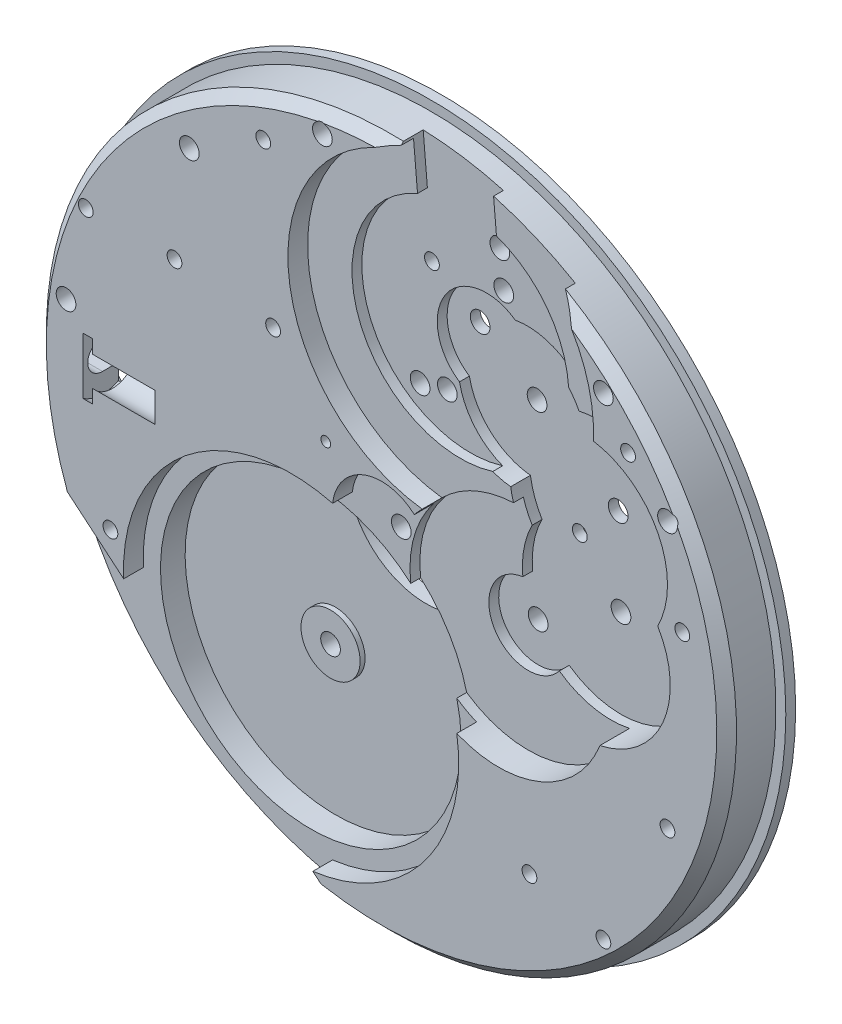
from build123d import *

# Parameters (mm, degrees)
CROQUIS1_R                           = 17.5
SALIENTE_EXTRUIR1_DEPTH              = 2.5
CROQUIS2_R                           = 18
SALIENTE_EXTRUIR2_DEPTH              = 0.5
CHAFL_N1_SIZE                        = 0.5
CROQUIS4_R                           = 7.625
CORTAR_EXTRUIR1_DEPTH                = 2.25
CROQUIS5_R                           = 7.75
CORTAR_EXTRUIR2_DEPTH                = 1
CROQUIS7_R                           = 0.5
CORTAR_EXTRUIR3_DEPTH                = 3
CROQUIS9_R                           = 1.5
SALIENTE_EXTRUIR3_DEPTH              = 0.25
CROQUIS10_R                          = 0.5
CORTAR_EXTRUIR4_DEPTH                = 2
CROQUIS8_R                           = 5.5
CORTAR_EXTRUIR5_DEPTH                = 2.0000001
CORTAR_EXTRUIR5_DEPTH_BACK           = 0.5
CORTAR_EXTRUIR6_DEPTH                = 0.5
CORTAR_EXTRUIR6_DIRECTION_2_REACH    = 3.5
CORTAR_EXTRUIR7_DEPTH                = 1
CORTAR_EXTRUIR7_DEPTH_BACK           = 0.5
CROQUIS14_R                          = 0.5
CORTAR_EXTRUIR8_DEPTH                = 2
DI_METRO_DE_TALADRO_1_0_1_1_D        = 1
DI_METRO_DE_TALADRO_1_0_1_1_DEPTH    = 1.25
DI_METRO_DE_TALADRO_1_0_1_1_TIP      = 0.30043031
TALADRO_ROSCADO_M1X0_251_D           = 0.75
TALADRO_ROSCADO_M1X0_251_DEPTH       = 1.5
TALADRO_ROSCADO_M1X0_251_TIP         = 0.225322732
CROQUIS19_R                          = 0.5
CORTAR_EXTRUIR9_DEPTH                = 2.5
CORTAR_EXTRUIR10_DEPTH               = 1.25
CROQUIS21_R                          = 4
CORTAR_EXTRUIR11_DEPTH               = 0.75
CROQUIS22_R                          = 0.25
CORTAR_EXTRUIR12_DEPTH               = 2.7500001
TALADRO_ROSCADO_M1X0_252_D           = 0.75
TALADRO_ROSCADO_M1X0_252_DEPTH       = 1.5
TALADRO_ROSCADO_M1X0_252_TIP         = 0.225322732
DI_METRO_DE_TALADRO_1_0_1_2_D        = 1
DI_METRO_DE_TALADRO_1_0_1_2_DEPTH    = 2
DI_METRO_DE_TALADRO_1_0_1_2_TIP      = 0.30043031
CHAFL_N2_SIZE                        = 0.25
TALADRO_ROSCADO_M1X0_253_D           = 0.75
TALADRO_ROSCADO_M1X0_253_DEPTH       = 1.25
TALADRO_ROSCADO_M1X0_253_CBORE_D     = 1
TALADRO_ROSCADO_M1X0_253_CBORE_DEPTH = 1
TALADRO_ROSCADO_M1X0_253_TIP         = 0.225322732
CROQUIS30_R                          = 0.75
CORTAR_EXTRUIR13_DEPTH               = 2.35
CROQUIS31_R                          = 1.75
CORTAR_EXTRUIR14_DEPTH               = 0.5
CORTAR_EXTRUIR15_DEPTH               = 1.2
CROQUIS33_R                          = 1.25
CORTAR_EXTRUIR16_DEPTH               = 3.15
DI_METRO_DE_TALADRO_0_2_0_2_1_D      = 0.2
DI_METRO_DE_TALADRO_0_2_0_2_1_DEPTH  = 2
DI_METRO_DE_TALADRO_0_2_0_2_1_TIP    = 0.060086062
CROQUIS38_R                          = 0.75
SALIENTE_EXTRUIR4_DEPTH              = 0.2
CORTAR_EXTRUIR17_REACH               = 3.8
CROQUIS42_R                          = 0.560779076
SALIENTE_EXTRUIR5_DEPTH              = 0.2
TALADRO_ROSCADO_M1X0_255_D           = 0.75
TALADRO_ROSCADO_M1X0_255_DEPTH       = 1
TALADRO_ROSCADO_M1X0_255_TIP         = 0.225322732
DI_METRO_DE_TALADRO_0_5_0_5_1_D      = 0.5
DI_METRO_DE_TALADRO_0_5_0_5_1_DEPTH  = 1
DI_METRO_DE_TALADRO_0_5_0_5_1_TIP    = 0.150215155
CROQUIS47_R                          = 0.25
CROQUIS47_R_2                        = 0.75
SALIENTE_EXTRUIR6_DEPTH              = 0.5
CROQUIS48_R                          = 2.5
CORTAR_EXTRUIR18_DEPTH               = 0.5
TALADRO_ROSCADO_M1X0_256_D           = 0.75


with BuildPart() as part:
    # Croquis1 → Saliente-Extruir1 (new body)
    with BuildSketch(Plane.XY):
        Circle(CROQUIS1_R)
    extrude(amount=SALIENTE_EXTRUIR1_DEPTH)

    # Croquis2 → Saliente-Extruir2 (add)
    with BuildSketch(Plane(origin=(0, 0, 0), x_dir=(-1, 0, 0), z_dir=(0, 0, -1))):
        Circle(CROQUIS2_R)
    extrude(amount=SALIENTE_EXTRUIR2_DEPTH)

    # Chaflán1
    chafl_n1_edges = [part.edges().sort_by_distance(p)[0] for p in [
        (-17.5, 0, 2.5),
    ]]
    chamfer(chafl_n1_edges, length=CHAFL_N1_SIZE)

    # Croquis4 → Cortar-Extruir1 (cut)
    with BuildSketch(Plane.XY.offset(2.5)):
        with Locations((-4.5875, -7.94578308)):
            Circle(CROQUIS4_R)
    extrude(amount=-CORTAR_EXTRUIR1_DEPTH, mode=Mode.SUBTRACT)

    # Croquis5 → Cortar-Extruir2 (cut)
    with BuildSketch(Plane.XY.offset(2.5)):
        with Locations((3, 10)):
            Circle(CROQUIS5_R)
        with BuildLine():
            Line((-1.637371781, -17.925373459), (-3.486082514, -16.374120966))
            ThreePointArc((-3.486082514, -16.374120966), (3.444053761, -10.728613327), (1.492398177, -2.005678858))
            ThreePointArc((1.492398177, -2.005678858), (1.25, 2.165063509), (-2.483167931, 0.289615304))
            ThreePointArc((-2.483167931, 0.289615304), (-9.949458217, -1.350375277), (-13.079051635, -8.324664114))
            Line((-13.079051635, -8.324664114), (-17.368720132, -4.72520486))
            ThreePointArc((-17.368720132, -4.72520486), (-11.570176974, -13.788799976), (-1.637371781, -17.925373459))
        make_face()
    extrude(amount=-CORTAR_EXTRUIR2_DEPTH, mode=Mode.SUBTRACT)

    # Croquis7 → Cortar-Extruir3 (cut, through all)
    with BuildSketch(Plane.XY.offset(1.5)):
        Circle(CROQUIS7_R)
    extrude(amount=-CORTAR_EXTRUIR3_DEPTH, mode=Mode.SUBTRACT)

    # Croquis9 → Saliente-Extruir3 (add)
    with BuildSketch(Plane.XY.offset(0.25)):
        with Locations((-4.5875, -7.94578308)):
            Circle(CROQUIS9_R)
    extrude(amount=SALIENTE_EXTRUIR3_DEPTH)

    # Croquis10 → Cortar-Extruir4 (cut, through all)
    with BuildSketch(Plane.XY.offset(0.5)):
        with Locations((-4.5875, -7.94578308)):
            Circle(CROQUIS10_R)
    extrude(amount=-CORTAR_EXTRUIR4_DEPTH, mode=Mode.SUBTRACT)

    # Croquis8 → Cortar-Extruir5 (cut, two sides)
    with BuildSketch(Plane.XY.offset(1.5)) as cortar_extruir5_sk:
        with Locations((5.940443832, -1.591737127)):
            Circle(CROQUIS8_R)
        with Locations((3, 10)):
            Circle(CROQUIS8_R)
    extrude(amount=CORTAR_EXTRUIR5_DEPTH, mode=Mode.SUBTRACT)
    extrude(cortar_extruir5_sk.sketch, amount=-CORTAR_EXTRUIR5_DEPTH_BACK, mode=Mode.SUBTRACT)

    # Croquis12 → Cortar-Extruir6 (cut)
    with BuildSketch(Plane.XY.offset(1)):
        with BuildLine():
            ThreePointArc((5.662662753, 0.388878351), (4.208393024, -2.591737127), (7.516816611, -2.822610337))
            ThreePointArc((7.516816611, -2.822610337), (13.187168015, -2.478659803), (14.002497063, 3.143299424))
            ThreePointArc((14.002497063, 3.143299424), (13.559245817, 7.953501265), (9.014598558, 9.590783985))
            ThreePointArc((9.014598558, 9.590783985), (7.458007143, 11.148033932), (5.279503391, 11.467604951))
            ThreePointArc((5.279503391, 11.467604951), (1.762906722, 10.848292533), (2.452427198, 7.344785503))
            ThreePointArc((2.452427198, 7.344785503), (3.53556337, 5.42780343), (5.549115697, 4.536954812))
            ThreePointArc((5.549115697, 4.536954812), (5.762848834, 3.684562771), (6.138169977, 2.889963448))
            ThreePointArc((6.138169977, 2.889963448), (5.71985462, 1.673749365), (5.662662753, 0.388878351))
        make_face()
    extrude(amount=-CORTAR_EXTRUIR6_DEPTH, mode=Mode.SUBTRACT)

    # Croquis12 → Cortar-Extruir6 direction 2 (cut, up to next)
    with BuildSketch(Plane.XY.offset(1), mode=Mode.PRIVATE) as cortar_extruir6_direction_2_sk1:
        with BuildLine():
            ThreePointArc((5.662662753, 0.388878351), (4.208393024, -2.591737127), (7.516816611, -2.822610337))
            ThreePointArc((7.516816611, -2.822610337), (13.187168015, -2.478659803), (14.002497063, 3.143299424))
            ThreePointArc((14.002497063, 3.143299424), (13.559245817, 7.953501265), (9.014598558, 9.590783985))
            ThreePointArc((9.014598558, 9.590783985), (7.458007143, 11.148033932), (5.279503391, 11.467604951))
            ThreePointArc((5.279503391, 11.467604951), (1.762906722, 10.848292533), (2.452427198, 7.344785503))
            ThreePointArc((2.452427198, 7.344785503), (3.53556337, 5.42780343), (5.549115697, 4.536954812))
            ThreePointArc((5.549115697, 4.536954812), (5.762848834, 3.684562771), (6.138169977, 2.889963448))
            ThreePointArc((6.138169977, 2.889963448), (5.71985462, 1.673749365), (5.662662753, 0.388878351))
        make_face()
    cortar_extruir6_direction_2_tool1 = extrude(cortar_extruir6_direction_2_sk1.sketch, amount=CORTAR_EXTRUIR6_DIRECTION_2_REACH, mode=Mode.PRIVATE) & part.part
    add(cortar_extruir6_direction_2_tool1.solids().sort_by_distance((8.561609, 4.064578, 1))[0], mode=Mode.SUBTRACT)

    # Croquis13 → Cortar-Extruir7 (cut, two sides)
    with BuildSketch(Plane.XY.offset(1.5)) as cortar_extruir7_sk:
        with BuildLine():
            ThreePointArc((4.827121442, 15.18764178), (2.812584682, 15.496805936), (0.823783861, 15.051146733))
            Line((0.823783861, 15.051146733), (1.334242107, 9.216582288))
            ThreePointArc((1.334242107, 9.216582288), (2.516063155, 11.564587625), (5.144709413, 11.557594655))
            Line((5.144709413, 11.557594655), (4.827121442, 15.18764178))
        make_face()
        with BuildLine():
            Line((4.534619214, 18.530957541), (0.549840422, 18.18233457))
            Line((0.549840422, 18.18233457), (0.620416939, 17.375641291))
            ThreePointArc((0.620416939, 17.375641291), (0.785026606, 17.426735007), (0.9507318, 17.47415546))
            ThreePointArc((0.9507318, 17.47415546), (2.83222679, 17.26929331), (4.680595206, 16.862444322))
            Line((4.680595206, 16.862444322), (4.534619214, 18.530957541))
        make_face()
        with BuildLine():
            ThreePointArc((0.9507318, 17.47415546), (0.785026606, 17.426735007), (0.620416939, 17.375641291))
            Line((0.620416939, 17.375641291), (0.823783861, 15.051146733))
            ThreePointArc((0.823783861, 15.051146733), (2.812584682, 15.496805936), (4.827121442, 15.18764178))
            Line((4.827121442, 15.18764178), (4.680595206, 16.862444322))
            ThreePointArc((4.680595206, 16.862444322), (2.83222679, 17.26929331), (0.9507318, 17.47415546))
        make_face()
    extrude(amount=CORTAR_EXTRUIR7_DEPTH, mode=Mode.SUBTRACT)
    extrude(cortar_extruir7_sk.sketch, amount=-CORTAR_EXTRUIR7_DEPTH_BACK, mode=Mode.SUBTRACT)

    # Croquis14 → Cortar-Extruir8 (cut, through all)
    with BuildSketch(Plane.XY.offset(0.5)):
        with Locations((3, 10)):
            Circle(CROQUIS14_R)
        with Locations((5.886550981, 8.020650756)):
            Circle(CROQUIS14_R)
        with Locations((10, 5.2)):
            Circle(CROQUIS14_R)
        with Locations((10.14066704, 0.833262873)):
            Circle(CROQUIS14_R)
        with Locations((5.940443832, -1.591737127)):
            Circle(CROQUIS14_R)
    extrude(amount=-CORTAR_EXTRUIR8_DEPTH, mode=Mode.SUBTRACT)

    # Diámetro de taladro Ø1.0 (1)1
    with Locations(Plane.XY.offset(2.5)):
        with Locations((-9.75, 12.25), (-3, 16.25), (-16, 2.5), (11.25, 12), (14.5, 8)):
            Hole(DI_METRO_DE_TALADRO_1_0_1_1_D / 2, depth=DI_METRO_DE_TALADRO_1_0_1_1_DEPTH)
            with Locations((0, 0, -(DI_METRO_DE_TALADRO_1_0_1_1_DEPTH + DI_METRO_DE_TALADRO_1_0_1_1_TIP / 2))):  # 118° drill point
                Cone(0, DI_METRO_DE_TALADRO_1_0_1_1_D / 2, DI_METRO_DE_TALADRO_1_0_1_1_TIP, mode=Mode.SUBTRACT)

    # Taladro roscado M1x0.251
    with Locations(Plane.XY.offset(2.5)):
        with Locations((-13.75, -6.5), (-5.5, 6.5), (-6, 14.5), (-10.5, 7), (7.5, -11), (14.5, -5.5), (12.5, 10), (11.25, -12)):
            Hole(TALADRO_ROSCADO_M1X0_251_D / 2, depth=TALADRO_ROSCADO_M1X0_251_DEPTH)
            with Locations((0, 0, -(TALADRO_ROSCADO_M1X0_251_DEPTH + TALADRO_ROSCADO_M1X0_251_TIP / 2))):  # 118° drill point
                Cone(0, TALADRO_ROSCADO_M1X0_251_D / 2, TALADRO_ROSCADO_M1X0_251_TIP, mode=Mode.SUBTRACT)

    # Croquis19 → Cortar-Extruir9 (cut, through all)
    with BuildSketch(Plane.XY.offset(1)):
        with Locations((1.835189814, 6.699512577)):
            Circle(CROQUIS19_R)
        with Locations((4.497613096, 14.24348383)):
            Circle(CROQUIS19_R)
    extrude(amount=-CORTAR_EXTRUIR9_DEPTH, mode=Mode.SUBTRACT)

    # Croquis20 → Cortar-Extruir10 (cut)
    with BuildSketch(Plane(origin=(0, 0, -0.5), x_dir=(-1, 0, 0), z_dir=(0, 0, -1))):
        with BuildLine():
            ThreePointArc((-0.012500625, 1.249937492), (-0.883883476, -0.883883476), (1.249937492, -0.012500625))
            ThreePointArc((1.249937492, -0.012500625), (5.126524164, 5.126524164), (-0.012500625, 1.249937492))
        make_face()
    extrude(amount=-CORTAR_EXTRUIR10_DEPTH, mode=Mode.SUBTRACT)

    # Croquis21 → Cortar-Extruir11 (cut)
    with BuildSketch(Plane(origin=(0, 0, -0.5), x_dir=(-1, 0, 0), z_dir=(0, 0, -1))):
        Circle(CROQUIS21_R)
    extrude(amount=-CORTAR_EXTRUIR11_DEPTH, mode=Mode.SUBTRACT)

    # Croquis22 → Cortar-Extruir12 (cut, through all)
    with BuildSketch(Plane(origin=(0, 0, 0.75), x_dir=(-1, 0, 0), z_dir=(0, 0, -1))):
        with Locations((2.828427125, 2.828427125)):
            Circle(CROQUIS22_R)
    extrude(amount=-CORTAR_EXTRUIR12_DEPTH, mode=Mode.SUBTRACT)

    # Taladro roscado M1x0.252
    with Locations(Plane.XY.offset(2.5)):
        with Locations((15.25, 3.5), (-15, 7)):
            Hole(TALADRO_ROSCADO_M1X0_252_D / 2, depth=TALADRO_ROSCADO_M1X0_252_DEPTH)
            with Locations((0, 0, -(TALADRO_ROSCADO_M1X0_252_DEPTH + TALADRO_ROSCADO_M1X0_252_TIP / 2))):  # 118° drill point
                Cone(0, TALADRO_ROSCADO_M1X0_252_D / 2, TALADRO_ROSCADO_M1X0_252_TIP, mode=Mode.SUBTRACT)

    # Diámetro de taladro Ø1.0 (1)2
    with Locations(Plane(origin=(0, 0, -0.5), x_dir=(-1, 0, 0), z_dir=(0, 0, -1))):
        with Locations((-9.899494937, -9.899494937), (9.899494937, 9.899494937)):
            Hole(DI_METRO_DE_TALADRO_1_0_1_2_D / 2, depth=DI_METRO_DE_TALADRO_1_0_1_2_DEPTH)
            with Locations((0, 0, -(DI_METRO_DE_TALADRO_1_0_1_2_DEPTH + DI_METRO_DE_TALADRO_1_0_1_2_TIP / 2))):  # 118° drill point
                Cone(0, DI_METRO_DE_TALADRO_1_0_1_2_D / 2, DI_METRO_DE_TALADRO_1_0_1_2_TIP, mode=Mode.SUBTRACT)

    # Chaflán2
    chafl_n2_edges = [part.edges().sort_by_distance(p)[0] for p in [
        (-10.399494937, 9.899494937, -0.5),
        (9.399494937, -9.899494937, -0.5),
    ]]
    chamfer(chafl_n2_edges, length=CHAFL_N2_SIZE)

    # Taladro roscado M1x0.253
    with Locations(Plane.XY.offset(1)):
        with Locations((0.4551224, 6.288720167), (4.696585067, 12.474186556)):
            CounterBoreHole(TALADRO_ROSCADO_M1X0_253_D / 2, TALADRO_ROSCADO_M1X0_253_CBORE_D / 2, TALADRO_ROSCADO_M1X0_253_CBORE_DEPTH, depth=TALADRO_ROSCADO_M1X0_253_DEPTH)
            with Locations((0, 0, -(TALADRO_ROSCADO_M1X0_253_DEPTH + TALADRO_ROSCADO_M1X0_253_TIP / 2))):  # 118° drill point
                Cone(0, TALADRO_ROSCADO_M1X0_253_D / 2, TALADRO_ROSCADO_M1X0_253_TIP, mode=Mode.SUBTRACT)

    # Croquis30 → Cortar-Extruir13 (cut)
    with BuildSketch(Plane.ZY.offset(17.5)):
        with Locations((1.5, 0)):
            Circle(CROQUIS30_R)
    extrude(amount=-CORTAR_EXTRUIR13_DEPTH, mode=Mode.SUBTRACT)

    # Croquis31 → Cortar-Extruir14 (cut)
    with BuildSketch(Plane.ZY.offset(15.15)):
        with Locations((1.5, 0)):
            Circle(CROQUIS31_R)
    extrude(amount=-CORTAR_EXTRUIR14_DEPTH, mode=Mode.SUBTRACT)

    # Croquis32 → Cortar-Extruir15 (cut)
    with BuildSketch(Plane(origin=(0, 0, -0.5), x_dir=(-1, 0, 0), z_dir=(0, 0, -1))):
        with BuildLine():
            Line((8.608181648, 6.180078921), (8.784958343, 6.356855616))
            ThreePointArc((8.784958343, 6.356855616), (9.072665102, 8.171396935), (10.901527338, 8.346320624))
            ThreePointArc((10.901527338, 8.346320624), (15.338146964, 7.225184058), (16.769401539, 2.878685324))
            ThreePointArc((16.769401539, 2.878685324), (17.196181265, 1.815699526), (17.19344713, 0.670242296))
            ThreePointArc((17.19344713, 0.670242296), (14.606289662, -3.763041104), (9.785714286, -1.999681097))
            ThreePointArc((9.785714286, -1.999681097), (8.60776645, -1.641737652), (7.862635069, -0.661705082))
            ThreePointArc((7.862635069, -0.661705082), (4.120596909, 3.207576346), (8.608181648, 6.180078921))
        make_face()
    extrude(amount=-CORTAR_EXTRUIR15_DEPTH, mode=Mode.SUBTRACT)

    # Croquis33 → Cortar-Extruir16 (cut)
    with BuildSketch(Plane.ZY.offset(14.65)):
        with Locations((1.5, 0)):
            Circle(CROQUIS33_R)
    extrude(amount=-CORTAR_EXTRUIR16_DEPTH, mode=Mode.SUBTRACT)

    # Diámetro de taladro Ø0.2 (0.2)1
    with Locations(Plane.ZY.offset(11.5)):
        with Locations((1.5, 0)):
            Hole(DI_METRO_DE_TALADRO_0_2_0_2_1_D / 2, depth=DI_METRO_DE_TALADRO_0_2_0_2_1_DEPTH)
            with Locations((0, 0, -(DI_METRO_DE_TALADRO_0_2_0_2_1_DEPTH + DI_METRO_DE_TALADRO_0_2_0_2_1_TIP / 2))):  # 118° drill point
                Cone(0, DI_METRO_DE_TALADRO_0_2_0_2_1_D / 2, DI_METRO_DE_TALADRO_0_2_0_2_1_TIP, mode=Mode.SUBTRACT)

    # Croquis38 → Saliente-Extruir4 (add)
    with BuildSketch(Plane(origin=(0, 0, 0.7), x_dir=(-1, 0, 0), z_dir=(0, 0, -1))):
        with Locations((7.6, 2.828427125)):
            Circle(CROQUIS38_R)
        with Locations((9.75, 0)):
            Circle(CROQUIS38_R)
    extrude(amount=SALIENTE_EXTRUIR4_DEPTH)

    # Croquis41 → Cortar-Extruir17 (cut, up to next)
    with BuildSketch(Plane(origin=(0, 0, 0.7), x_dir=(-1, 0, 0), z_dir=(0, 0, -1)), mode=Mode.PRIVATE) as cortar_extruir17_sk1:
        with BuildLine():
            Line((15.15, 0.75), (17.179058411, 0.75))
            ThreePointArc((17.179058411, 0.75), (17.25, 0), (17.179058411, -0.75))
            Line((17.179058411, -0.75), (15.15, -0.75))
            Line((15.15, -0.75), (15.15, 0.75))
        make_face()
    cortar_extruir17_tool1 = extrude(cortar_extruir17_sk1.sketch, amount=-CORTAR_EXTRUIR17_REACH, mode=Mode.PRIVATE) & part.part
    add(cortar_extruir17_tool1.solids().sort_by_distance((-16.188326, 0, 0.7))[0], mode=Mode.SUBTRACT)

    # Croquis42 → Saliente-Extruir5 (add)
    with BuildSketch(Plane(origin=(0, 0, 0.7), x_dir=(-1, 0, 0), z_dir=(0, 0, -1))):
        with Locations((13.328427125, -2.171572875)):
            Circle(CROQUIS42_R)
    extrude(amount=SALIENTE_EXTRUIR5_DEPTH)

    # Taladro roscado M1x0.255
    with Locations(Plane(origin=(0, 0, 0.5), x_dir=(-1, 0, 0), z_dir=(0, 0, -1))):
        with Locations((13.328427125, -2.171572875), (7.6, 2.828427125)):
            Hole(TALADRO_ROSCADO_M1X0_255_D / 2, depth=TALADRO_ROSCADO_M1X0_255_DEPTH)
            with Locations((0, 0, -(TALADRO_ROSCADO_M1X0_255_DEPTH + TALADRO_ROSCADO_M1X0_255_TIP / 2))):  # 118° drill point
                Cone(0, TALADRO_ROSCADO_M1X0_255_D / 2, TALADRO_ROSCADO_M1X0_255_TIP, mode=Mode.SUBTRACT)

    # Diámetro de taladro Ø0.5 (0.5)1
    with Locations(Plane(origin=(0, 0, 0.7), x_dir=(-1, 0, 0), z_dir=(0, 0, -1))):
        with Locations((15.4, 3.056438242)):
            Hole(DI_METRO_DE_TALADRO_0_5_0_5_1_D / 2, depth=DI_METRO_DE_TALADRO_0_5_0_5_1_DEPTH)
            with Locations((0, 0, -(DI_METRO_DE_TALADRO_0_5_0_5_1_DEPTH + DI_METRO_DE_TALADRO_0_5_0_5_1_TIP / 2))):  # 118° drill point
                Cone(0, DI_METRO_DE_TALADRO_0_5_0_5_1_D / 2, DI_METRO_DE_TALADRO_0_5_0_5_1_TIP, mode=Mode.SUBTRACT)

    # Croquis47 → Saliente-Extruir6 (add)
    with BuildSketch(Plane(origin=(0, 0, 0.7), x_dir=(-1, 0, 0), z_dir=(0, 0, -1))):
        with Locations((12.35, 7.5)):
            Circle(CROQUIS47_R)
        with Locations((10.1, 7.078427125)):
            Circle(CROQUIS47_R_2)
    extrude(amount=SALIENTE_EXTRUIR6_DEPTH)

    # Croquis48 → Cortar-Extruir18 (cut)
    with BuildSketch(Plane(origin=(0, 0, -0.5), x_dir=(-1, 0, 0), z_dir=(0, 0, -1))):
        with Locations((-9, 4.2)):
            Circle(CROQUIS48_R)
        with Locations((-2, 11)):
            Circle(CROQUIS48_R)
    extrude(amount=-CORTAR_EXTRUIR18_DEPTH, mode=Mode.SUBTRACT)

    # Taladro roscado M1x0.256 (through all)
    with Locations(Plane(origin=(0, 0, 0), x_dir=(-1, 0, 0), z_dir=(0, 0, -1))):
        with Locations((-8.055456352, 3.255456352), (-1.055456352, 11.944543648)):
            Hole(TALADRO_ROSCADO_M1X0_256_D / 2)


solid = part.part
